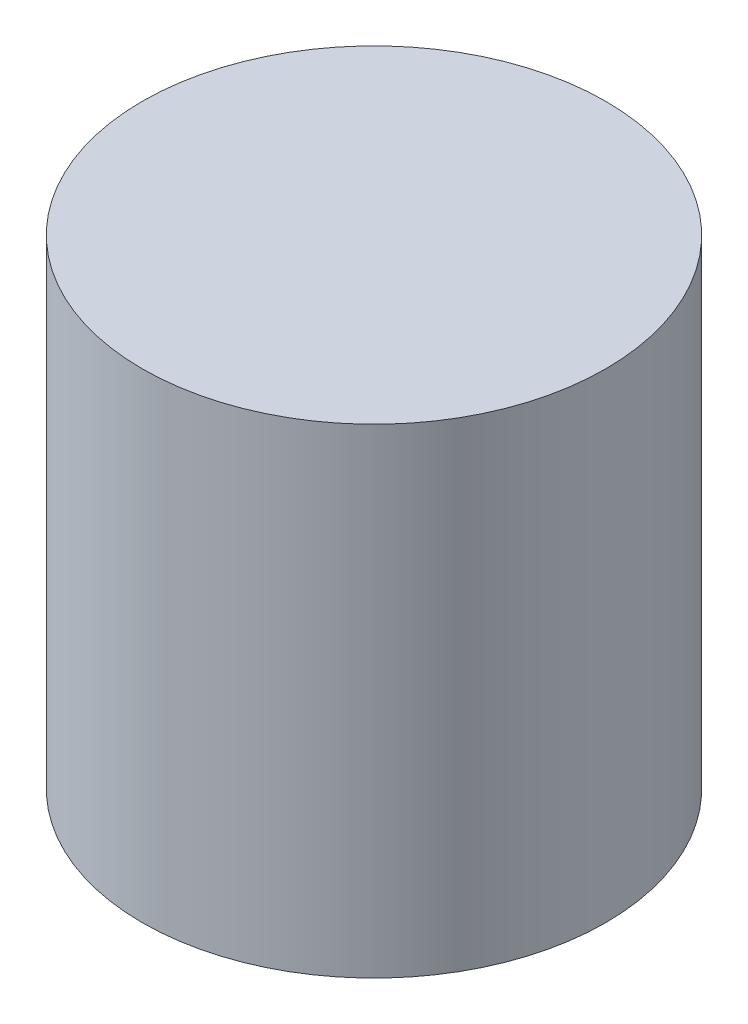
from build123d import *

# Parameters (mm, degrees)
SKETCH1_R           = 11
BOSS_EXTRUDE1_DEPTH = 22.77


with BuildPart() as part:
    # Sketch1 → Boss-Extrude1 (new body)
    with BuildSketch(Plane(origin=(0, 0, 0), x_dir=(1, 0, 0), z_dir=(0, 1, 0))):
        with Locations((-15.32076311, 23.227019559)):
            Circle(SKETCH1_R)
    extrude(amount=BOSS_EXTRUDE1_DEPTH)


solid = part.part
